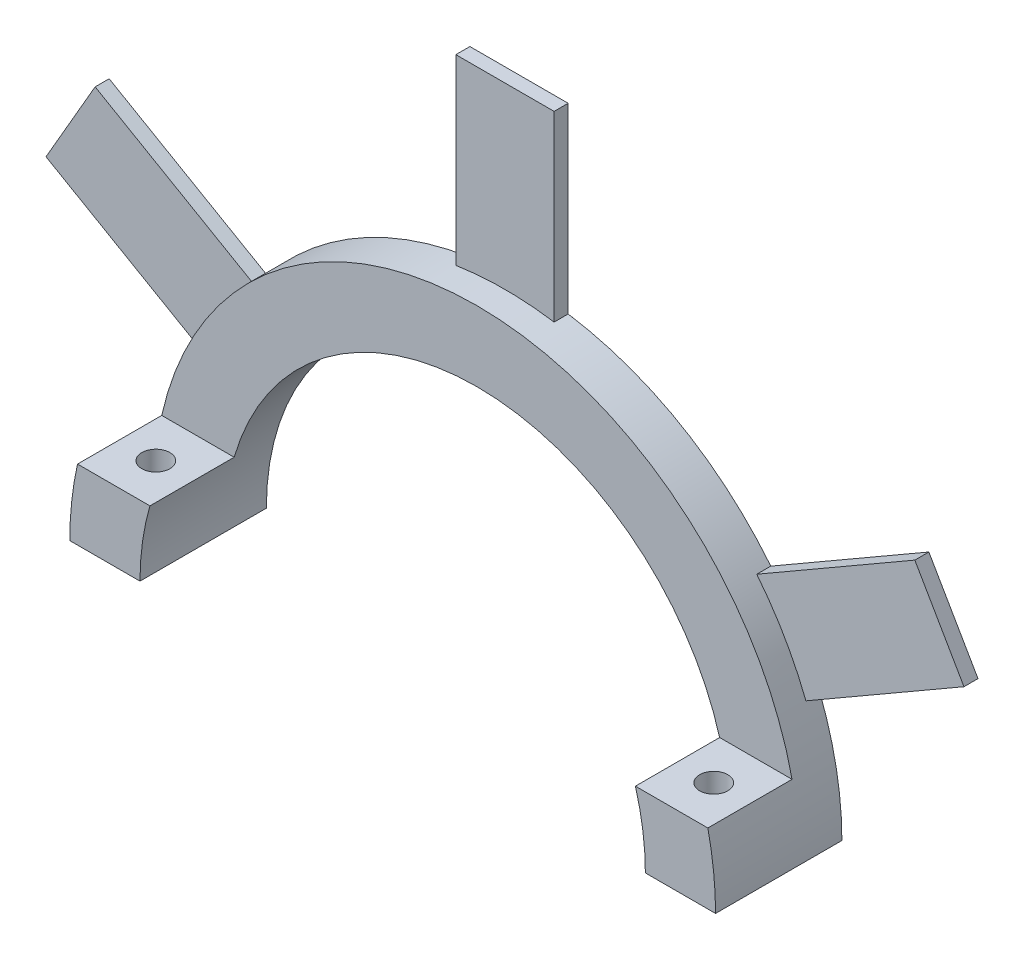
from build123d import *

# Parameters (mm, degrees)
BOSS_EXTRUDE1_DEPTH = 3
BOSS_EXTRUDE2_DEPTH = 6
SKETCH4_R           = 1
CUT_EXTRUDE1_DEPTH  = 5
CUT_EXTRUDE2_DEPTH  = 2


with BuildPart() as part:
    # Sketch1 → Boss-Extrude1 (new body)
    with BuildSketch(Plane.XY):
        with BuildLine():
            Line((32.694937372, 14.834979008), (29.194937372, 20.897156835))
            Line((29.194937372, 20.897156835), (17.936607123, 14.397156835))
            ThreePointArc((17.936607123, 14.397156835), (11.5, 19.918584287), (3.5, 22.732135843))
            Line((3.5, 22.732135843), (3.5, 35.732135843))
            Line((3.5, 35.732135843), (-3.5, 35.732135843))
            Line((-3.5, 35.732135843), (-3.5, 22.732135843))
            ThreePointArc((-3.5, 22.732135843), (-11.5, 19.918584287), (-17.936607123, 14.397156835))
            Line((-17.936607123, 14.397156835), (-29.194937372, 20.897156835))
            Line((-29.194937372, 20.897156835), (-32.694937372, 14.834979008))
            Line((-32.694937372, 14.834979008), (-21.436607123, 8.334979008))
            ThreePointArc((-21.436607123, 8.334979008), (-22.605773199, 4.240167224), (-23, 0))
            Line((-23, 0), (-18, 0))
            ThreePointArc((-18, 0), (0, 18), (18, 0))
            Line((18, 0), (23, 0))
            ThreePointArc((23, 0), (22.605773199, 4.240167224), (21.436607123, 8.334979008))
            Line((21.436607123, 8.334979008), (32.694937372, 14.834979008))
        make_face()
    extrude(amount=BOSS_EXTRUDE1_DEPTH)

    # Sketch2 → Boss-Extrude2 (add)
    with BuildSketch(Plane.XY.offset(3)):
        with BuildLine():
            Line((-17.291616466, 5), (-22.449944321, 5))
            ThreePointArc((-22.449944321, 5), (-22.862072515, 2.515082566), (-23, 0))
            Line((-23, 0), (-18, 0))
            ThreePointArc((-18, 0), (-17.822024245, 2.524965704), (-17.291616466, 5))
        make_face()
        with BuildLine():
            Line((22.449944321, 5), (17.291616466, 5))
            ThreePointArc((17.291616466, 5), (17.822024245, 2.524965704), (18, 0))
            Line((18, 0), (23, 0))
            ThreePointArc((23, 0), (22.862072515, 2.515082566), (22.449944321, 5))
        make_face()
    extrude(amount=BOSS_EXTRUDE2_DEPTH)

    # Sketch4 → Cut-Extrude1 (cut)
    with BuildSketch(Plane(origin=(0, 5, 0), x_dir=(1, 0, 0), z_dir=(0, 1, 0))):
        with Locations((-19.870780393, -6)):
            Circle(SKETCH4_R)
        with Locations((19.870780393, -6)):
            Circle(SKETCH4_R)
    extrude(amount=-CUT_EXTRUDE1_DEPTH, mode=Mode.SUBTRACT)

    # Sketch5 → Cut-Extrude2 (cut)
    with BuildSketch(Plane.XY.offset(3)):
        with BuildLine():
            Line((-32.694937372, 14.834979008), (-21.436607123, 8.334979008))
            ThreePointArc((-21.436607123, 8.334979008), (-19.918584287, 11.5), (-17.936607123, 14.397156835))
            Line((-17.936607123, 14.397156835), (-29.194937372, 20.897156835))
            Line((-29.194937372, 20.897156835), (-32.694937372, 14.834979008))
        make_face()
        with BuildLine():
            ThreePointArc((-3.5, 22.732135843), (0, 23), (3.5, 22.732135843))
            Line((3.5, 22.732135843), (3.5, 35.732135843))
            Line((3.5, 35.732135843), (-3.5, 35.732135843))
            Line((-3.5, 35.732135843), (-3.5, 22.732135843))
        make_face()
        with BuildLine():
            ThreePointArc((17.936607123, 14.397156835), (19.918584287, 11.5), (21.436607123, 8.334979008))
            Line((21.436607123, 8.334979008), (32.694937372, 14.834979008))
            Line((32.694937372, 14.834979008), (29.194937372, 20.897156835))
            Line((29.194937372, 20.897156835), (17.936607123, 14.397156835))
        make_face()
    extrude(amount=-CUT_EXTRUDE2_DEPTH, mode=Mode.SUBTRACT)


solid = part.part
